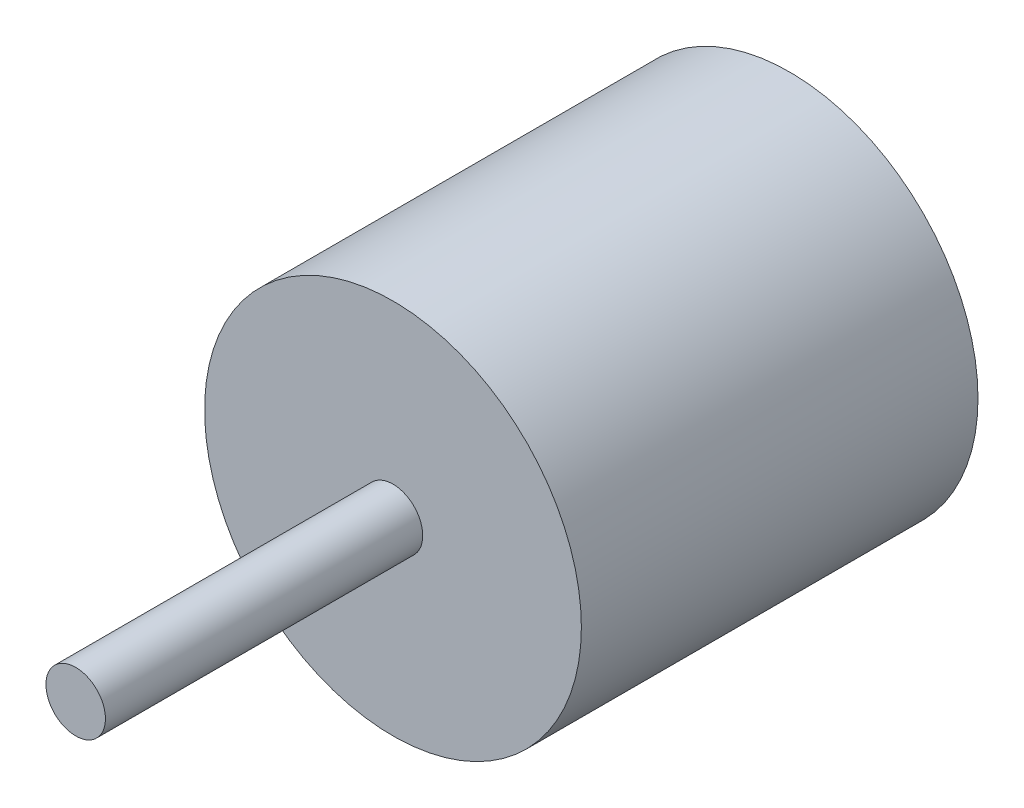
from build123d import *

# Parameters (mm, degrees)
SKETCH1_R           = 19
BOSS_EXTRUDE1_DEPTH = 40
SKETCH3_R           = 3
BOSS_EXTRUDE2_DEPTH = 32


with BuildPart() as part:
    # Sketch1 → Boss-Extrude1 (new body)
    with BuildSketch(Plane.XY):
        with Locations((26.387220358, 15.380786198)):
            Circle(SKETCH1_R)
    extrude(amount=BOSS_EXTRUDE1_DEPTH)

    # Sketch3 → Boss-Extrude2 (add)
    with BuildSketch(Plane.XY.offset(40)):
        with Locations((26.387220358, 15.380786198)):
            Circle(SKETCH3_R)
    extrude(amount=BOSS_EXTRUDE2_DEPTH)


solid = part.part
